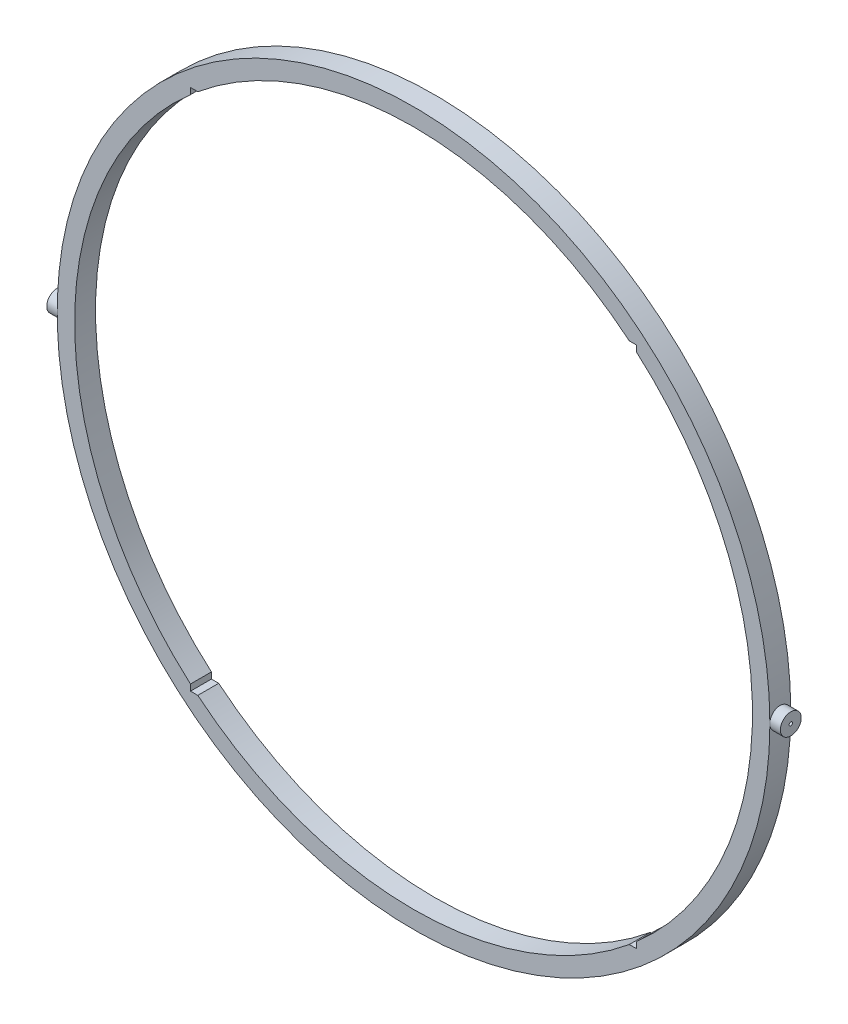
from build123d import *

# Parameters (mm, degrees)
SKETCH1_R           = 102.24716621
SKETCH1_R_2         = 97.24716621
BOSS_EXTRUDE1_DEPTH = 6
SKETCH3_R           = 3
SKETCH3_R_2         = 0.5
BOSS_EXTRUDE2_DEPTH = 8
SKETCH4_R           = 3
SKETCH4_R_2         = 0.5
BOSS_EXTRUDE3_DEPTH = 8
CUT_EXTRUDE3_DEPTH  = 10


with BuildPart() as part:
    # Sketch1 → Boss-Extrude1 (new body)
    with BuildSketch(Plane.XY):
        Circle(SKETCH1_R)
        Circle(SKETCH1_R_2, mode=Mode.SUBTRACT)
    extrude(amount=BOSS_EXTRUDE1_DEPTH)

    # Sketch5 → Cut-Extrude3 (cut)
    with BuildSketch(Plane.XY.offset(6)):
        Polygon((-64, 73.218927443), (-64, 75), (-61.903241723, 75), align=None)
        Polygon((64, 73.218927443), (61.903241723, 75), (64, 75), align=None)
        Polygon((64, -75), (61.903241723, -75), (64, -73.218927443), align=None)
        Polygon((-64, -73.218927443), (-61.903241723, -75), (-64, -75), align=None)
    extrude(amount=-CUT_EXTRUDE3_DEPTH, mode=Mode.SUBTRACT)


with BuildPart() as body_2:
    # Sketch3 → Boss-Extrude2 (new body)
    with BuildSketch(Plane(origin=(-97.24716621, 0, 0), x_dir=(0, 0, -1), z_dir=(1, 0, 0))):
        with Locations((-3, 0)):
            Circle(SKETCH3_R)
        with Locations((-3, 0)):
            Circle(SKETCH3_R_2, mode=Mode.SUBTRACT)
    extrude(amount=-BOSS_EXTRUDE2_DEPTH)


with BuildPart() as body_3:
    # Sketch4 → Boss-Extrude3 (new body)
    with BuildSketch(Plane.ZY.offset(-97.24716621)):
        with Locations((3, 0)):
            Circle(SKETCH4_R)
        with Locations((3, 0)):
            Circle(SKETCH4_R_2, mode=Mode.SUBTRACT)
    extrude(amount=-BOSS_EXTRUDE3_DEPTH)


solid = Compound([part.part, body_2.part, body_3.part])
